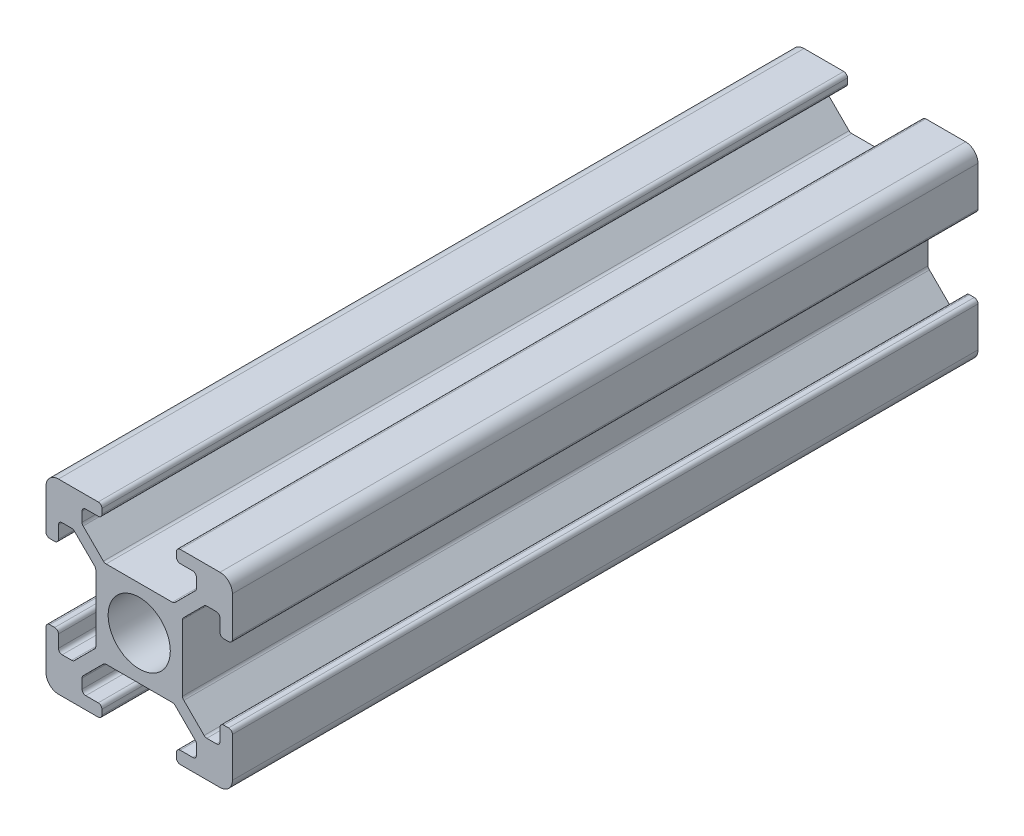
from build123d import *

# Parameters (mm, degrees)
SKETCH1_R           = 2.5
BOSS_EXTRUDE1_DEPTH = 60


with BuildPart() as part:
    # Sketch1 → Boss-Extrude1 (new body)
    with BuildSketch(Plane.XY):
        with BuildLine():
            Line((0.997149379, -0.010991612), (4.197149379, -0.010991612))
            ThreePointArc((4.197149379, -0.010991612), (4.409281413, 0.076876353), (4.497149379, 0.289008388))
            Line((4.497149379, 0.289008388), (4.497149379, 0.689008388))
            ThreePointArc((4.497149379, 0.689008388), (4.409281413, 0.901140422), (4.197149379, 0.989008388))
            Line((4.197149379, 0.989008388), (3.197149379, 0.989008388))
            ThreePointArc((3.197149379, 0.989008388), (2.985017344, 1.076876353), (2.897149379, 1.289008388))
            Line((2.897149379, 1.289008388), (2.897149379, 2.057637538))
            ThreePointArc((2.897149379, 2.057637538), (2.920422177, 2.174637797), (2.9866975, 2.273825827))
            Line((2.9866975, 2.273825827), (4.61806835, 3.905196677))
            ThreePointArc((4.61806835, 3.905196677), (4.71725638, 3.971472), (4.834256639, 3.994744798))
            Line((4.834256639, 3.994744798), (10.171514939, 3.994744798))
            ThreePointArc((10.171514939, 3.994744798), (10.288515198, 3.971472), (10.387703228, 3.905196677))
            Line((10.387703228, 3.905196677), (12.019074078, 2.273825827))
            ThreePointArc((12.019074078, 2.273825827), (12.085349401, 2.174637797), (12.1086222, 2.057637538))
            Line((12.1086222, 2.057637538), (12.1086222, 1.289008388))
            ThreePointArc((12.1086222, 1.289008388), (12.020754234, 1.076876353), (11.8086222, 0.989008388))
            Line((11.8086222, 0.989008388), (10.797149379, 0.989008388))
            ThreePointArc((10.797149379, 0.989008388), (10.585017344, 0.901140422), (10.497149379, 0.689008388))
            Line((10.497149379, 0.689008388), (10.497149379, 0.289008388))
            ThreePointArc((10.497149379, 0.289008388), (10.585017344, 0.076876353), (10.797149379, -0.010991612))
            Line((10.797149379, -0.010991612), (13.997149379, -0.010991612))
            ThreePointArc((13.997149379, -0.010991612), (14.70425616, 0.281901607), (14.997149379, 0.989008388))
            Line((14.997149379, 0.989008388), (14.997149379, 4.189008388))
            ThreePointArc((14.997149379, 4.189008388), (14.909281413, 4.401140422), (14.697149379, 4.489008388))
            Line((14.697149379, 4.489008388), (14.305261888, 4.489008388))
            ThreePointArc((14.305261888, 4.489008388), (14.093129854, 4.401140422), (14.005261888, 4.189008388))
            Line((14.005261888, 4.189008388), (14.005261888, 3.189008388))
            ThreePointArc((14.005261888, 3.189008388), (13.917393922, 2.976876353), (13.705261888, 2.889008388))
            Line((13.705261888, 2.889008388), (12.936632738, 2.889008388))
            ThreePointArc((12.936632738, 2.889008388), (12.819632479, 2.912281186), (12.720444449, 2.978556509))
            Line((12.720444449, 2.978556509), (11.089073599, 4.609927359))
            ThreePointArc((11.089073599, 4.609927359), (11.006246661, 4.70520219), (10.969948855, 4.826115648))
            Line((10.969948855, 4.826115648), (10.969948855, 10.163373948))
            ThreePointArc((10.969948855, 10.163373948), (11.00546556, 10.284783861), (11.087867966, 10.380761184))
            Line((11.087867966, 10.380761184), (12.719238816, 12.012132034))
            ThreePointArc((12.719238816, 12.012132034), (12.81656582, 12.07716386), (12.93137085, 12.1))
            Line((12.93137085, 12.1), (13.7, 12.1))
            ThreePointArc((13.7, 12.1), (13.912132034, 12.012132034), (14, 11.8))
            Line((14, 11.8), (14, 10.8))
            ThreePointArc((14, 10.8), (14.087867966, 10.587867966), (14.3, 10.5))
            Line((14.3, 10.5), (14.697149379, 10.5))
            ThreePointArc((14.697149379, 10.5), (14.909281413, 10.587867966), (14.997149379, 10.8))
            Line((14.997149379, 10.8), (14.997149379, 13.989008388))
            ThreePointArc((14.997149379, 13.989008388), (14.70425616, 14.696115169), (13.997149379, 14.989008388))
            Line((13.997149379, 14.989008388), (10.797149379, 14.989008388))
            ThreePointArc((10.797149379, 14.989008388), (10.585017344, 14.901140422), (10.497149379, 14.689008388))
            Line((10.497149379, 14.689008388), (10.497149379, 14.289008388))
            ThreePointArc((10.497149379, 14.289008388), (10.585017344, 14.076876353), (10.797149379, 13.989008388))
            Line((10.797149379, 13.989008388), (11.798829534, 13.989008388))
            ThreePointArc((11.798829534, 13.989008388), (12.010961569, 13.901140422), (12.098829534, 13.689008388))
            Line((12.098829534, 13.689008388), (12.098829534, 12.916322983))
            ThreePointArc((12.098829534, 12.916322983), (12.075993394, 12.801517953), (12.010961569, 12.704190949))
            Line((12.010961569, 12.704190949), (10.379590719, 11.072820099))
            ThreePointArc((10.379590719, 11.072820099), (10.282263714, 11.007788273), (10.167458684, 10.984952133))
            Line((10.167458684, 10.984952133), (4.830200384, 10.984952133))
            ThreePointArc((4.830200384, 10.984952133), (4.715395355, 11.007788273), (4.61806835, 11.072820099))
            Line((4.61806835, 11.072820099), (2.9866975, 12.704190949))
            ThreePointArc((2.9866975, 12.704190949), (2.920422177, 12.803378979), (2.897149379, 12.920379238))
            Line((2.897149379, 12.920379238), (2.897149379, 13.689008388))
            ThreePointArc((2.897149379, 13.689008388), (2.985017344, 13.901140422), (3.197149379, 13.989008388))
            Line((3.197149379, 13.989008388), (4.197149379, 13.989008388))
            ThreePointArc((4.197149379, 13.989008388), (4.409281413, 14.076876353), (4.497149379, 14.289008388))
            Line((4.497149379, 14.289008388), (4.497149379, 14.689008388))
            ThreePointArc((4.497149379, 14.689008388), (4.409281413, 14.901140422), (4.197149379, 14.989008388))
            Line((4.197149379, 14.989008388), (0.997149379, 14.989008388))
            ThreePointArc((0.997149379, 14.989008388), (0.290042597, 14.696115169), (-0.002850621, 13.989008388))
            Line((-0.002850621, 13.989008388), (-0.002850621, 10.789008388))
            ThreePointArc((-0.002850621, 10.789008388), (0.085017344, 10.576876353), (0.297149379, 10.489008388))
            Line((0.297149379, 10.489008388), (0.697149379, 10.489008388))
            ThreePointArc((0.697149379, 10.489008388), (0.909281413, 10.576876353), (0.997149379, 10.789008388))
            Line((0.997149379, 10.789008388), (0.997149379, 11.790199043))
            ThreePointArc((0.997149379, 11.790199043), (1.085017344, 12.002331078), (1.297149379, 12.090199043))
            Line((1.297149379, 12.090199043), (2.057928823, 12.090199043))
            ThreePointArc((2.057928823, 12.090199043), (2.174143192, 12.067250491), (2.272911478, 12.001849869))
            Line((2.272911478, 12.001849869), (3.912132034, 10.380761184))
            ThreePointArc((3.912132034, 10.380761184), (3.97928656, 10.281159192), (4.002885789, 10.163373948))
            Line((4.002885789, 10.163373948), (4.002885789, 4.826115648))
            ThreePointArc((4.002885789, 4.826115648), (3.979612991, 4.709115389), (3.913337668, 4.609927359))
            Line((3.913337668, 4.609927359), (2.281966818, 2.978556509))
            ThreePointArc((2.281966818, 2.978556509), (2.182778788, 2.912281186), (2.065778529, 2.889008388))
            Line((2.065778529, 2.889008388), (1.297149379, 2.889008388))
            ThreePointArc((1.297149379, 2.889008388), (1.085017344, 2.976876353), (0.997149379, 3.189008388))
            Line((0.997149379, 3.189008388), (0.997149379, 4.189008388))
            ThreePointArc((0.997149379, 4.189008388), (0.909281413, 4.401140422), (0.697149379, 4.489008388))
            Line((0.697149379, 4.489008388), (0.297149379, 4.489008388))
            ThreePointArc((0.297149379, 4.489008388), (0.085017344, 4.401140422), (-0.002850621, 4.189008388))
            Line((-0.002850621, 4.189008388), (-0.002850621, 0.989008388))
            ThreePointArc((-0.002850621, 0.989008388), (0.290042597, 0.281901607), (0.997149379, -0.010991612))
        make_face()
        with Locations((7.5, 7.5)):
            Circle(SKETCH1_R, mode=Mode.SUBTRACT)
    extrude(amount=BOSS_EXTRUDE1_DEPTH)


solid = part.part
